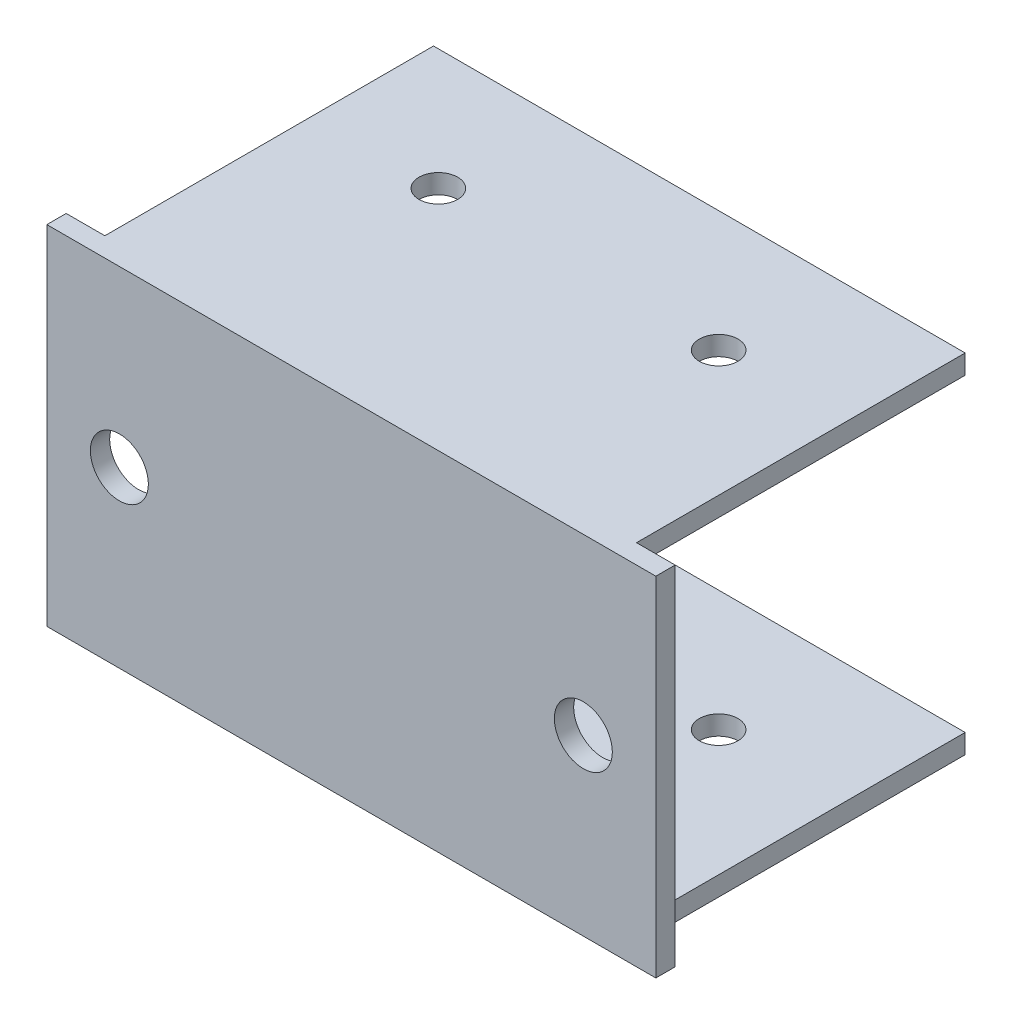
from build123d import *

# Parameters (mm, degrees)
SKETCH_1_W          = 63
SKETCH_1_H          = 36
EXTRUDE_1_DEPTH     = 2
SKETCH_2_R          = 3
CUT_EXTRUDE_1_DEPTH = 10
SKETCH_4_W          = 55
SKETCH_4_H          = 36
EXTRUDE_2_DEPTH     = 2
SKETCH_5_R          = 2
CUT_EXTRUDE_2_DEPTH = 37


with BuildPart() as part:
    # 草图1 → 凸台-拉伸1 (new body)
    with BuildSketch(Plane.XY):
        Rectangle(SKETCH_1_W, SKETCH_1_H)
    extrude(amount=EXTRUDE_1_DEPTH)

    # 草图2 → 切除-拉伸1 (cut)
    with BuildSketch(Plane.XY.offset(2)):
        with Locations((-24, 0)):
            Circle(SKETCH_2_R)
        with Locations((24, 0)):
            Circle(SKETCH_2_R)
    extrude(amount=-CUT_EXTRUDE_1_DEPTH, mode=Mode.SUBTRACT)

    # 草图4 → 凸台-拉伸2 (add)
    with BuildSketch(Plane(origin=(0, 18, 0), x_dir=(1, 0, 0), z_dir=(0, 1, 0))):
        with Locations((0, 16)):
            Rectangle(SKETCH_4_W, SKETCH_4_H)
    extrude_2 = extrude(amount=-EXTRUDE_2_DEPTH)

    # 草图5 → 切除-拉伸2 (cut, through all)
    with BuildSketch(Plane(origin=(0, 18, 0), x_dir=(1, 0, 0), z_dir=(0, 1, 0))):
        with Locations((-14.5, 21.5)):
            Circle(SKETCH_5_R)
        with Locations((14.5, 21.5)):
            Circle(SKETCH_5_R)
    cut_extrude_2 = extrude(amount=-CUT_EXTRUDE_2_DEPTH, mode=Mode.SUBTRACT)

    # 镜向1: 凸台-拉伸2, 切除-拉伸2 across plane
    add(extrude_2.mirror(Plane.ZX))
    add(cut_extrude_2.mirror(Plane.ZX), mode=Mode.SUBTRACT)


solid = part.part
